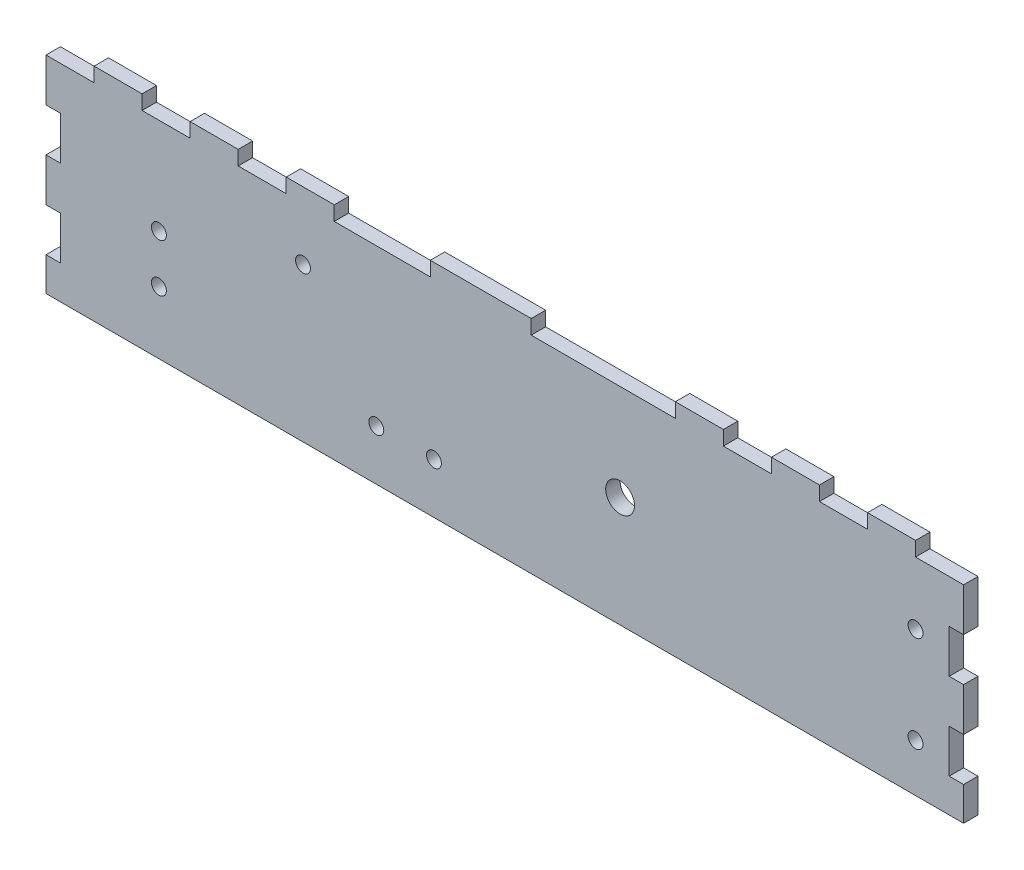
from build123d import *

# Parameters (mm, degrees)
SKETCH1_W           = 191
SKETCH1_H           = 46
SKETCH1_R           = 1.549999948
BOSS_EXTRUDE1_DEPTH = 3
CUT_EXTRUDE1_REACH  = 5
SKETCH4_W           = 10
SKETCH4_H           = 3
SKETCH4_W_2         = 20
SKETCH4_W_3         = 30
CUT_EXTRUDE2_REACH  = 5
SKETCH5_W           = 3
SKETCH5_H           = 9
CUT_EXTRUDE3_REACH  = 5
SKETCH6_W           = 3
SKETCH6_H           = 9
CUT_EXTRUDE4_REACH  = 5
SKETCH7_R           = 3
CUT_EXTRUDE5_REACH  = 5
SKETCH8_R           = 1.55


with BuildPart() as part:
    # Sketch1 → Boss-Extrude1 (new body)
    with BuildSketch(Plane.XY):
        with Locations((95.5, 23)):
            Rectangle(SKETCH1_W, SKETCH1_H)
        with Locations((181, 30)):
            Circle(SKETCH1_R, mode=Mode.SUBTRACT)
        with Locations((181, 10)):
            Circle(SKETCH1_R, mode=Mode.SUBTRACT)
    extrude(amount=BOSS_EXTRUDE1_DEPTH)

    # Sketch4 → Cut-Extrude1 (cut, up to next)
    with BuildSketch(Plane(origin=(0, 0, 0), x_dir=(-1, 0, 0), z_dir=(0, 0, -1)), mode=Mode.PRIVATE) as cut_extrude1_sk1:
        with Locations((-5, 44.5)):
            Rectangle(SKETCH4_W, SKETCH4_H)
    cut_extrude1_tool1 = extrude(cut_extrude1_sk1.sketch, amount=-CUT_EXTRUDE1_REACH, mode=Mode.PRIVATE) & part.part
    add(cut_extrude1_tool1.solids().sort_by_distance((5, 44.5, 0))[0], mode=Mode.SUBTRACT)
    # Sketch4 → Cut-Extrude1 (cut, up to next)
    with BuildSketch(Plane(origin=(0, 0, 0), x_dir=(-1, 0, 0), z_dir=(0, 0, -1)), mode=Mode.PRIVATE) as cut_extrude1_sk2:
        with Locations((-25, 44.5)):
            Rectangle(SKETCH4_W, SKETCH4_H)
    cut_extrude1_tool2 = extrude(cut_extrude1_sk2.sketch, amount=-CUT_EXTRUDE1_REACH, mode=Mode.PRIVATE) & part.part
    add(cut_extrude1_tool2.solids().sort_by_distance((25, 44.5, 0))[0], mode=Mode.SUBTRACT)
    # Sketch4 → Cut-Extrude1 (cut, up to next)
    with BuildSketch(Plane(origin=(0, 0, 0), x_dir=(-1, 0, 0), z_dir=(0, 0, -1)), mode=Mode.PRIVATE) as cut_extrude1_sk3:
        with Locations((-45, 44.5)):
            Rectangle(SKETCH4_W, SKETCH4_H)
    cut_extrude1_tool3 = extrude(cut_extrude1_sk3.sketch, amount=-CUT_EXTRUDE1_REACH, mode=Mode.PRIVATE) & part.part
    add(cut_extrude1_tool3.solids().sort_by_distance((45, 44.5, 0))[0], mode=Mode.SUBTRACT)
    # Sketch4 → Cut-Extrude1 (cut, up to next)
    with BuildSketch(Plane(origin=(0, 0, 0), x_dir=(-1, 0, 0), z_dir=(0, 0, -1)), mode=Mode.PRIVATE) as cut_extrude1_sk4:
        with Locations((-70, 44.5)):
            Rectangle(SKETCH4_W_2, SKETCH4_H)
    cut_extrude1_tool4 = extrude(cut_extrude1_sk4.sketch, amount=-CUT_EXTRUDE1_REACH, mode=Mode.PRIVATE) & part.part
    add(cut_extrude1_tool4.solids().sort_by_distance((70, 44.5, 0))[0], mode=Mode.SUBTRACT)
    # Sketch4 → Cut-Extrude1 (cut, up to next)
    with BuildSketch(Plane(origin=(0, 0, 0), x_dir=(-1, 0, 0), z_dir=(0, 0, -1)), mode=Mode.PRIVATE) as cut_extrude1_sk5:
        with Locations((-116, 44.5)):
            Rectangle(SKETCH4_W_3, SKETCH4_H)
    cut_extrude1_tool5 = extrude(cut_extrude1_sk5.sketch, amount=-CUT_EXTRUDE1_REACH, mode=Mode.PRIVATE) & part.part
    add(cut_extrude1_tool5.solids().sort_by_distance((116, 44.5, 0))[0], mode=Mode.SUBTRACT)
    # Sketch4 → Cut-Extrude1 (cut, up to next)
    with BuildSketch(Plane(origin=(0, 0, 0), x_dir=(-1, 0, 0), z_dir=(0, 0, -1)), mode=Mode.PRIVATE) as cut_extrude1_sk6:
        with Locations((-146, 44.5)):
            Rectangle(SKETCH4_W, SKETCH4_H)
    cut_extrude1_tool6 = extrude(cut_extrude1_sk6.sketch, amount=-CUT_EXTRUDE1_REACH, mode=Mode.PRIVATE) & part.part
    add(cut_extrude1_tool6.solids().sort_by_distance((146, 44.5, 0))[0], mode=Mode.SUBTRACT)
    # Sketch4 → Cut-Extrude1 (cut, up to next)
    with BuildSketch(Plane(origin=(0, 0, 0), x_dir=(-1, 0, 0), z_dir=(0, 0, -1)), mode=Mode.PRIVATE) as cut_extrude1_sk7:
        with Locations((-166, 44.5)):
            Rectangle(SKETCH4_W, SKETCH4_H)
    cut_extrude1_tool7 = extrude(cut_extrude1_sk7.sketch, amount=-CUT_EXTRUDE1_REACH, mode=Mode.PRIVATE) & part.part
    add(cut_extrude1_tool7.solids().sort_by_distance((166, 44.5, 0))[0], mode=Mode.SUBTRACT)
    # Sketch4 → Cut-Extrude1 (cut, up to next)
    with BuildSketch(Plane(origin=(0, 0, 0), x_dir=(-1, 0, 0), z_dir=(0, 0, -1)), mode=Mode.PRIVATE) as cut_extrude1_sk8:
        with Locations((-186, 44.5)):
            Rectangle(SKETCH4_W, SKETCH4_H)
    cut_extrude1_tool8 = extrude(cut_extrude1_sk8.sketch, amount=-CUT_EXTRUDE1_REACH, mode=Mode.PRIVATE) & part.part
    add(cut_extrude1_tool8.solids().sort_by_distance((186, 44.5, 0))[0], mode=Mode.SUBTRACT)

    # Sketch5 → Cut-Extrude2 (cut, up to next)
    with BuildSketch(Plane(origin=(0, 0, 0), x_dir=(-1, 0, 0), z_dir=(0, 0, -1)), mode=Mode.PRIVATE) as cut_extrude2_sk1:
        with Locations((-1.5, 29.5)):
            Rectangle(SKETCH5_W, SKETCH5_H)
    cut_extrude2_tool1 = extrude(cut_extrude2_sk1.sketch, amount=-CUT_EXTRUDE2_REACH, mode=Mode.PRIVATE) & part.part
    add(cut_extrude2_tool1.solids().sort_by_distance((1.5, 29.5, 0))[0], mode=Mode.SUBTRACT)
    # Sketch5 → Cut-Extrude2 (cut, up to next)
    with BuildSketch(Plane(origin=(0, 0, 0), x_dir=(-1, 0, 0), z_dir=(0, 0, -1)), mode=Mode.PRIVATE) as cut_extrude2_sk2:
        with Locations((-1.5, 11.5)):
            Rectangle(SKETCH5_W, SKETCH5_H)
    cut_extrude2_tool2 = extrude(cut_extrude2_sk2.sketch, amount=-CUT_EXTRUDE2_REACH, mode=Mode.PRIVATE) & part.part
    add(cut_extrude2_tool2.solids().sort_by_distance((1.5, 11.5, 0))[0], mode=Mode.SUBTRACT)

    # Sketch6 → Cut-Extrude3 (cut, up to next)
    with BuildSketch(Plane(origin=(0, 0, 0), x_dir=(-1, 0, 0), z_dir=(0, 0, -1)), mode=Mode.PRIVATE) as cut_extrude3_sk1:
        with Locations((-189.5, 29.5)):
            Rectangle(SKETCH6_W, SKETCH6_H)
    cut_extrude3_tool1 = extrude(cut_extrude3_sk1.sketch, amount=-CUT_EXTRUDE3_REACH, mode=Mode.PRIVATE) & part.part
    add(cut_extrude3_tool1.solids().sort_by_distance((189.5, 29.5, 0))[0], mode=Mode.SUBTRACT)
    # Sketch6 → Cut-Extrude3 (cut, up to next)
    with BuildSketch(Plane(origin=(0, 0, 0), x_dir=(-1, 0, 0), z_dir=(0, 0, -1)), mode=Mode.PRIVATE) as cut_extrude3_sk2:
        with Locations((-189.5, 11.5)):
            Rectangle(SKETCH6_W, SKETCH6_H)
    cut_extrude3_tool2 = extrude(cut_extrude3_sk2.sketch, amount=-CUT_EXTRUDE3_REACH, mode=Mode.PRIVATE) & part.part
    add(cut_extrude3_tool2.solids().sort_by_distance((189.5, 11.5, 0))[0], mode=Mode.SUBTRACT)

    # Sketch7 → Cut-Extrude4 (cut, up to next)
    with BuildSketch(Plane.XY.offset(3), mode=Mode.PRIVATE) as cut_extrude4_sk1:
        with Locations((119.5, 23)):
            Circle(SKETCH7_R)
    cut_extrude4_tool1 = extrude(cut_extrude4_sk1.sketch, amount=-CUT_EXTRUDE4_REACH, mode=Mode.PRIVATE) & part.part
    add(cut_extrude4_tool1.solids().sort_by_distance((119.5, 23, 3))[0], mode=Mode.SUBTRACT)

    # Sketch8 → Cut-Extrude5 (cut, up to next)
    with BuildSketch(Plane.XY.offset(3), mode=Mode.PRIVATE) as cut_extrude5_sk1:
        with Locations((23.5, 13)):
            Circle(SKETCH8_R)
    cut_extrude5_tool1 = extrude(cut_extrude5_sk1.sketch, amount=-CUT_EXTRUDE5_REACH, mode=Mode.PRIVATE) & part.part
    add(cut_extrude5_tool1.solids().sort_by_distance((23.5, 13, 3))[0], mode=Mode.SUBTRACT)
    # Sketch8 → Cut-Extrude5 (cut, up to next)
    with BuildSketch(Plane.XY.offset(3), mode=Mode.PRIVATE) as cut_extrude5_sk2:
        with Locations((23.5, 23)):
            Circle(SKETCH8_R)
    cut_extrude5_tool2 = extrude(cut_extrude5_sk2.sketch, amount=-CUT_EXTRUDE5_REACH, mode=Mode.PRIVATE) & part.part
    add(cut_extrude5_tool2.solids().sort_by_distance((23.5, 23, 3))[0], mode=Mode.SUBTRACT)
    # Sketch8 → Cut-Extrude5 (cut, up to next)
    with BuildSketch(Plane.XY.offset(3), mode=Mode.PRIVATE) as cut_extrude5_sk3:
        with Locations((53.5, 32)):
            Circle(SKETCH8_R)
    cut_extrude5_tool3 = extrude(cut_extrude5_sk3.sketch, amount=-CUT_EXTRUDE5_REACH, mode=Mode.PRIVATE) & part.part
    add(cut_extrude5_tool3.solids().sort_by_distance((53.5, 32, 3))[0], mode=Mode.SUBTRACT)
    # Sketch8 → Cut-Extrude5 (cut, up to next)
    with BuildSketch(Plane.XY.offset(3), mode=Mode.PRIVATE) as cut_extrude5_sk4:
        with Locations((68.757359313, 10.5)):
            Circle(SKETCH8_R)
    cut_extrude5_tool4 = extrude(cut_extrude5_sk4.sketch, amount=-CUT_EXTRUDE5_REACH, mode=Mode.PRIVATE) & part.part
    add(cut_extrude5_tool4.solids().sort_by_distance((68.757359, 10.5, 3))[0], mode=Mode.SUBTRACT)
    # Sketch8 → Cut-Extrude5 (cut, up to next)
    with BuildSketch(Plane.XY.offset(3), mode=Mode.PRIVATE) as cut_extrude5_sk5:
        with Locations((80.757359313, 10.5)):
            Circle(SKETCH8_R)
    cut_extrude5_tool5 = extrude(cut_extrude5_sk5.sketch, amount=-CUT_EXTRUDE5_REACH, mode=Mode.PRIVATE) & part.part
    add(cut_extrude5_tool5.solids().sort_by_distance((80.757359, 10.5, 3))[0], mode=Mode.SUBTRACT)


solid = part.part
